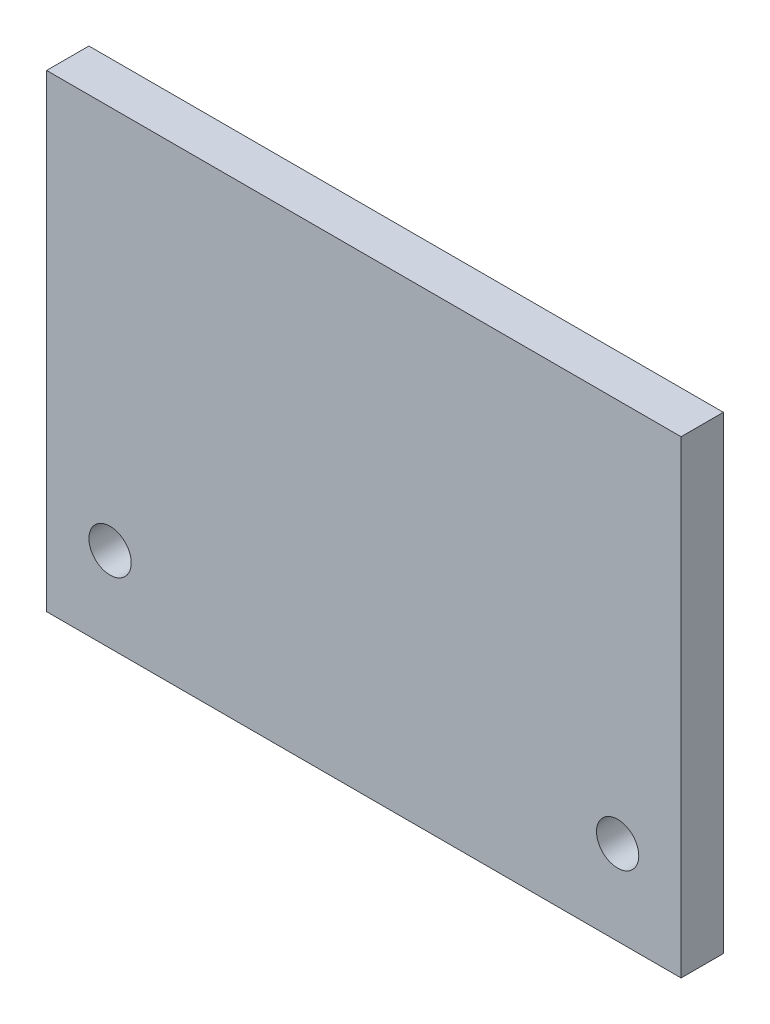
from build123d import *

# Parameters (mm, degrees)
SKETCH1_W           = 95.25
SKETCH1_H           = 70.374561309
BOSS_EXTRUDE1_DEPTH = 6.35
SKETCH2_R           = 3.175
CUT_EXTRUDE1_DEPTH  = 6.35


with BuildPart() as part:
    # Sketch1 → Boss-Extrude1 (new body)
    with BuildSketch(Plane.XY):
        with Locations((41.275, 63.390258975)):
            Rectangle(SKETCH1_W, SKETCH1_H)
    extrude(amount=-BOSS_EXTRUDE1_DEPTH)

    # Sketch2 → Cut-Extrude1 (cut)
    with BuildSketch(Plane.XY):
        with Locations((79.375, 40.90297832)):
            Circle(SKETCH2_R)
        with Locations((3.175, 40.90297832)):
            Circle(SKETCH2_R)
    extrude(amount=-CUT_EXTRUDE1_DEPTH, mode=Mode.SUBTRACT)


solid = part.part
